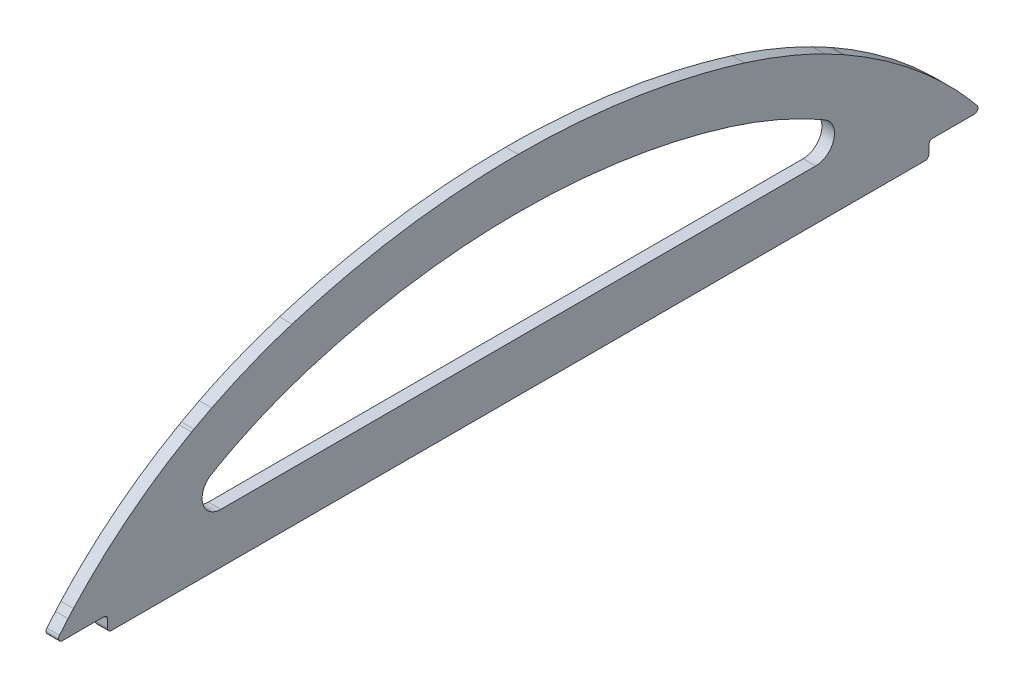
from build123d import *

# Parameters (mm, degrees)
BOSS_EXTRUDE1_DEPTH = 2.54
FILLET1_R           = 3.81
FILLET2_R           = 0.762


with BuildPart() as part:
    # Sketch1 → Boss-Extrude1 (new body)
    with BuildSketch(Plane(origin=(0, 0, 0), x_dir=(0, 0, -1), z_dir=(1, 0, 0))):
        with BuildLine():
            Line((-83.086605292, 9.124512034), (-83.086605292, 5.949512034))
            Line((-83.086605292, 5.9495121), (83.08693495, 5.949512039))
            Line((83.08693495, 5.949512034), (83.08693495, 9.124512034))
            Line((83.08693495, 9.124512034), (93.855087571, 9.124512034))
            add(Edge.make_bspline(
                [(93.855087571, 9.124512034), (93.669390634, 9.356272796), (93.48301693, 9.586708655), (93.295980098, 9.815819191)],
                knots=[0.958874258, 0.958874258, 0.958874258, 0.958874258, 0.999999994, 0.999999994, 0.999999994, 0.999999994], degree=3))
            add(Edge.make_bspline(
                [(93.295980098, 9.815819191), (92.573520354, 10.700820031), (91.837407927, 11.570093885), (91.088607202, 12.423653516)],
                knots=[0, 0, 0, 0, 0.999999969, 0.999999969, 0.999999969, 0.999999969], degree=3))
            add(Edge.make_bspline(
                [(91.088607202, 12.423653516), (90.732403903, 12.829720301), (90.3691814, 13.23653123), (89.999295568, 13.644198602)],
                knots=[0, 0, 0, 0, 0.999998817, 0.999998817, 0.999998817, 0.999998817], degree=3))
            add(Edge.make_bspline(
                [(89.999295568, 13.644198602), (88.263736645, 15.557402446), (86.456850424, 17.383811689), (83.656265812, 19.992945204), (81.877677334, 21.582877917), (79.959433977, 23.172016193), (79.003672378, 23.933569864), (78.880201436, 24.031580116), (78.8500855, 24.055456495), (74.766434879, 27.288849464), (70.49844929, 30.137419925), (66.0898283, 32.625549015)],
                knots=[0, 0, 0, 0, 0.25, 0.25, 0.375, 0.484375, 0.49609375, 0.49609375, 0.5, 0.5, 1, 1, 1, 1], degree=3))
            add(Edge.make_bspline(
                [(66.0898283, 32.625549015), (65.937726203, 32.711362281), (65.785374882, 32.796833698), (65.632786792, 32.881972811)],
                knots=[0, 0, 0, 0, 0.999999332, 0.999999332, 0.999999332, 0.999999332], degree=3))
            add(Edge.make_bspline(
                [(65.632786792, 32.881972811), (64.438991281, 33.547917605), (63.233047485, 34.188591406), (62.016280537, 34.804134833)],
                knots=[0, 0, 0, 0, 0.188270319, 0.188270319, 0.188270319, 0.188270319], degree=3))
            add(Edge.make_bspline(
                [(45.773443183, 41.367307224), (46.698409203, 41.072281164), (48.549711138, 40.481792104), (51.296482177, 39.49900755), (54.021069902, 38.445016196), (56.717966474, 37.311104313), (59.38867901, 36.105971196), (61.140001019, 35.238284581), (62.016280537, 34.804134833)],
                knots=[0, 0, 0, 0, 0.166059502, 0.332364941, 0.498914452, 0.665705307, 0.832734591, 1, 1, 1, 1], degree=3))
            add(Edge.make_bspline(
                [(2.77e-06, 48.225559846), (1.295691838, 48.216706127), (3.88555224, 48.199009061), (7.765917508, 48.050927927), (11.637576629, 47.814179387), (15.498714941, 47.480233554), (19.347496819, 47.051554295), (23.182050278, 46.527574564), (27.000474791, 45.908521452), (30.800744354, 45.194147538), (34.581005743, 44.385011656), (38.338400636, 43.478655031), (42.073394606, 42.483647239), (44.540083523, 41.73942362), (45.773443183, 41.367307224)],
                knots=[0, 0, 0, 0, 0.083667004, 0.167236003, 0.250718828, 0.334127208, 0.417472666, 0.500766405, 0.584019192, 0.667241242, 0.750442094, 0.833630483, 0.916814216, 1, 1, 1, 1], degree=3))
            add(Edge.make_bspline(
                [(-45.77360361, 41.367307212), (-44.540239378, 41.739424273), (-42.073541319, 42.483649221), (-38.338533575, 43.478658558), (-34.581124876, 44.385016402), (-30.800849651, 45.194153145), (-27.000566232, 45.908527574), (-23.182127849, 46.527580854), (-19.347560514, 47.051560407), (-15.498764759, 47.480239142), (-11.637612577, 47.814184109), (-7.765939601, 48.050931432), (-3.885560492, 48.19901103), (-1.295690897, 48.216706784), (2.77e-06, 48.225559846)],
                knots=[0, 0, 0, 0, 0.083185784, 0.166369517, 0.249557906, 0.332758758, 0.415980808, 0.499233595, 0.582527334, 0.665872792, 0.749281172, 0.832763997, 0.916332996, 1, 1, 1, 1], degree=3))
            add(Edge.make_bspline(
                [(-62.016440965, 34.804134821), (-61.140161446, 35.238284569), (-59.388839437, 36.105971185), (-56.718126901, 37.311104302), (-54.021230329, 38.445016184), (-51.296642604, 39.499007538), (-48.549871565, 40.481792093), (-46.69856963, 41.072281152), (-45.77360361, 41.367307212)],
                knots=[0, 0, 0, 0, 0.167265409, 0.334294693, 0.501085548, 0.667635059, 0.833940498, 1, 1, 1, 1], degree=3))
            add(Edge.make_bspline(
                [(-65.632946452, 32.881973224), (-65.334103086, 33.047535139), (-64.736601165, 33.378556583), (-63.83418796, 33.863161989), (-62.928164638, 34.339625855), (-62.32028641, 34.649330314), (-62.016440965, 34.804134821)],
                knots=[0, 0, 0, 0, 0.250231692, 0.500308635, 0.750231315, 1, 1, 1, 1], degree=3))
            add(Edge.make_bspline(
                [(-66.089988266, 32.625549258), (-65.93788607, 32.71136258), (-65.785534648, 32.796834053), (-65.632946452, 32.881973224)],
                knots=[9.1e-08, 9.1e-08, 9.1e-08, 9.1e-08, 1, 1, 1, 1], degree=3))
            add(Edge.make_bspline(
                [(-89.999452425, 13.644202231), (-89.731580263, 13.937236014), (-89.196347847, 14.522743588), (-88.379707216, 15.3866898), (-87.554261183, 16.239060342), (-86.719198635, 17.078888781), (-85.875046519, 17.906426532), (-84.455855617, 19.262563161), (-82.716732176, 20.842262901), (-80.932828401, 22.364264435), (-79.729547155, 23.353230066), (-78.452111939, 24.37733563), (-76.784085286, 25.662071142), (-74.706149634, 27.176301329), (-72.596634386, 28.630814042), (-70.456863816, 30.02421632), (-68.291749321, 31.361638543), (-66.823062702, 32.20473128), (-66.089988266, 32.625549258)],
                knots=[0, 0, 0, 0, 0.038849538, 0.077624833, 0.11632675, 0.154956063, 0.193513464, 0.231999567, 0.347035183, 0.423377364, 0.461444905, 0.499443712, 0.583587956, 0.66744402, 0.751012861, 0.834294992, 0.917290657, 1, 1, 1, 1], degree=3))
            add(Edge.make_bspline(
                [(-91.088767221, 12.423653818), (-90.909347195, 12.627255178), (-90.548803909, 13.036390686), (-90.183145386, 13.440961308), (-89.999452425, 13.644202231)],
                knots=[0, 0, 0, 0, 0.497637961, 1, 1, 1, 1], degree=3))
            add(Edge.make_bspline(
                [(-93.296140089, 9.815819534), (-93.054512448, 10.109651163), (-92.571752336, 10.69671227), (-91.835828208, 11.566016825), (-91.337618576, 12.137968805), (-91.088767221, 12.423653818)],
                knots=[0, 0, 0, 0, 0.334015544, 0.667346586, 1, 1, 1, 1], degree=3))
            add(Edge.make_bspline(
                [(-93.854757913, 9.124512034), (-93.669213364, 9.355476446), (-93.482676726, 9.58564799), (-93.296140089, 9.815819534)],
                knots=[0.818363249, 0.818363249, 0.818363249, 0.818363249, 1, 1, 1, 1], degree=3))
            Line((-93.854757913, 9.124512034), (-83.086605292, 9.124512034))
        make_face()
        with BuildLine():
            add(Edge.make_bspline(
                [(61.096812302, 23.77708068), (63.086876526, 22.653808398), (66.003993561, 20.857958692), (69.650668566, 18.31053447), (71.499677463, 16.912768408), (72.407499066, 16.197438356), (72.518532607, 16.109512034)],
                knots=[0, 0, 0, 0, 0.249993096, 0.374989644, 0.484671819, 0.500050493, 0.500050493, 0.500050493, 0.500050493], degree=3))
            Line((72.518532607, 16.109512034), (-72.518692987, 16.109512034))
            add(Edge.make_bspline(
                [(-72.518692966, 16.109512051), (-72.295058744, 16.286622022), (-71.394956692, 16.992213663), (-69.567305628, 18.367078286), (-67.45827822, 19.843450975), (-65.54498621, 21.099976692), (-64.322538483, 21.871500696), (-63.36250442, 22.457135326), (-62.646065511, 22.882377789), (-61.882985895, 23.325457334), (-61.334816007, 23.640227801), (-61.065465968, 23.794848292)],
                knots=[0.499115184, 0.499115184, 0.499115184, 0.499115184, 0.530325631, 0.62420894, 0.749050727, 0.811471621, 0.873892515, 0.905102962, 0.936313409, 0.967523856, 0.998734303, 0.998734303, 0.998734303, 0.998734303], degree=3))
            add(Edge.make_bspline(
                [(-61.065465968, 23.794848292), (-61.034721548, 23.812178605), (-60.973236004, 23.846794097), (-60.880821708, 23.898693104), (-60.788287634, 23.950531422), (-60.726475583, 23.985074316), (-60.695571461, 24.002323714)],
                knots=[0.077725822, 0.077725822, 0.077725822, 0.077725822, 0.300433276, 0.523140729, 0.745848182, 0.968555635, 0.968555635, 0.968555635, 0.968555635], degree=3))
            add(Edge.make_bspline(
                [(-60.695571461, 24.002323714), (-60.553908863, 24.080805783), (-60.262424838, 24.242246747), (-59.743662045, 24.527389713), (-59.084994337, 24.881211243), (-58.416950037, 25.232799353), (-57.893970152, 25.501725644), (-57.598476575, 25.652369452), (-57.454904735, 25.725520705)],
                knots=[0.003841396, 0.003841396, 0.003841396, 0.003841396, 0.126618025, 0.249394654, 0.494947912, 0.74050117, 0.863277799, 0.986054428, 0.986054428, 0.986054428, 0.986054428], degree=3))
            add(Edge.make_bspline(
                [(-57.454904735, 25.725520705), (-57.138365226, 25.882346452), (-56.494616132, 26.201151648), (-55.590341911, 26.643039537), (-54.730597394, 27.05210074), (-53.564894563, 27.587764955), (-52.05219946, 28.252438901), (-50.240684694, 29.007010268), (-48.413636112, 29.721991861), (-46.861197777, 30.295369174), (-45.645417281, 30.722050698), (-44.740361667, 31.026594236), (-43.782655138, 31.337862891), (-43.098785175, 31.556162004), (-42.762367548, 31.663470244)],
                knots=[0.003251414, 0.003251414, 0.003251414, 0.003251414, 0.065262937, 0.127274461, 0.189285984, 0.251297507, 0.375320553, 0.4993436, 0.623366646, 0.747389692, 0.809401215, 0.871412739, 0.933424262, 0.995435785, 0.995435785, 0.995435785, 0.995435785], degree=3))
            add(Edge.make_bspline(
                [(-42.762367548, 31.663470244), (-42.308777847, 31.800318864), (-41.391060757, 32.077036553), (-40.075539043, 32.466779001), (-38.803886944, 32.830140125), (-37.088806261, 33.297623685), (-34.895529163, 33.859706667), (-31.391477046, 34.691585002), (-26.981644563, 35.604260179), (-21.64714693, 36.502037757), (-16.280054956, 37.199812535), (-11.789958663, 37.616041283), (-8.187495018, 37.847698273), (-5.920954392, 37.954373339), (-4.138377257, 38.012069827), (-2.809617361, 38.039540075), (-1.433349527, 38.055394519), (-0.474326709, 38.062079255), (7.2e-08, 38.065322552)],
                knots=[0.001722186, 0.001722186, 0.001722186, 0.001722186, 0.032871639, 0.064021091, 0.095170543, 0.126319996, 0.1886189, 0.250917805, 0.375515614, 0.500113423, 0.624711232, 0.749309041, 0.811607946, 0.87390685, 0.905056302, 0.936205755, 0.967355207, 0.998504659, 0.998504659, 0.998504659, 0.998504659], degree=3))
            add(Edge.make_bspline(
                [(7.2e-08, 38.065322552), (0.47432516, 38.062079015), (1.433344593, 38.055393792), (2.80960734, 38.039538673), (4.138362145, 38.01206782), (5.920932503, 37.954370597), (8.187464637, 37.847694717), (11.789914662, 37.616036665), (16.279993911, 37.199807065), (21.647065397, 36.50203201), (26.981542552, 35.604254912), (31.391357977, 34.691580772), (34.89539651, 33.859703648), (37.088665109, 33.297621573), (38.803738968, 32.830138864), (40.075386035, 32.46677842), (41.390902758, 32.077036676), (42.308616515, 31.800319456), (42.762204551, 31.663471076)],
                knots=[0.001495346, 0.001495346, 0.001495346, 0.001495346, 0.0326448, 0.063794253, 0.094943707, 0.126093161, 0.188392068, 0.250690976, 0.375288791, 0.499886606, 0.624484421, 0.749082236, 0.811381143, 0.873680051, 0.904829504, 0.935978958, 0.967128412, 0.998277866, 0.998277866, 0.998277866, 0.998277866], degree=3))
            add(Edge.make_bspline(
                [(42.762204551, 31.663471076), (43.098876928, 31.556081578), (43.783275826, 31.337613361), (44.741655076, 31.026117835), (45.647348491, 30.721334421), (46.864131187, 30.294256721), (48.417805086, 29.720357834), (50.246111379, 29.004765242), (52.059107386, 28.249422095), (53.572858092, 27.584134487), (54.739075266, 27.048067996), (55.599753332, 26.638414336), (56.50523956, 26.195837468), (57.149838608, 25.876583733), (57.466804416, 25.719545657)],
                knots=[0.004564061, 0.004564061, 0.004564061, 0.004564061, 0.066623656, 0.128683251, 0.190742846, 0.252802441, 0.376921632, 0.501040822, 0.625160012, 0.749279203, 0.811338798, 0.873398393, 0.935457988, 0.997517583, 0.997517583, 0.997517583, 0.997517583], degree=3))
            add(Edge.make_bspline(
                [(57.466804416, 25.719545657), (57.737576994, 25.582413293), (58.277751844, 25.30547357), (59.083932262, 24.88196866), (59.885873711, 24.450393344), (60.417629509, 24.157281849), (60.682750942, 24.009388894)],
                knots=[2.5397e-05, 2.5397e-05, 2.5397e-05, 2.5397e-05, 0.046559042, 0.093092686, 0.13962633, 0.186159974, 0.186159974, 0.186159974, 0.186159974], degree=3))
            add(Edge.make_bspline(
                [(60.682750942, 24.009388894), (60.717355826, 23.990080292), (60.786570391, 23.951407853), (60.890161629, 23.893369132), (60.993602639, 23.835254288), (61.062407721, 23.796490778), (61.096812302, 23.77708068)],
                knots=[0.001593987, 0.001593987, 0.001593987, 0.001593987, 0.250933156, 0.500272325, 0.749611495, 0.998950664, 0.998950664, 0.998950664, 0.998950664], degree=3))
        make_face(mode=Mode.SUBTRACT)
    extrude(amount=BOSS_EXTRUDE1_DEPTH)

    # Fillet1
    fillet1_edges = [part.edges().sort_by_distance(p)[0] for p in [
        (1.27, 16.109512034, -72.518532607),
        (1.27, 16.109512043, 72.518692977),
    ]]
    fillet(fillet1_edges, radius=FILLET1_R)

    # Fillet2
    fillet2_edges = [part.edges().sort_by_distance(p)[0] for p in [
        (1.27, 5.949512067, 83.086605292),
        (1.27, 9.124512034, 83.086605292),
        (1.27, 9.124512034, 93.854757913),
        (1.27, 9.124512034, -93.855087571),
        (1.27, 9.124512034, -83.08693495),
        (1.27, 5.949512037, -83.08693495),
    ]]
    fillet(fillet2_edges, radius=FILLET2_R)


solid = part.part
